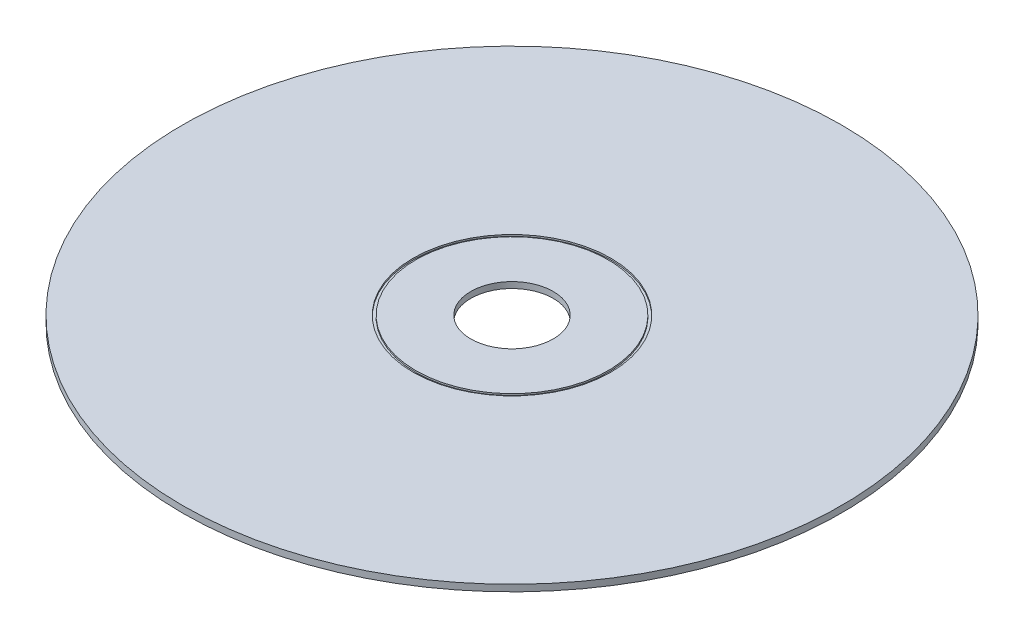
from build123d import *

# Parameters (mm, degrees)
SKETCH1_R           = 60
SKETCH1_R_2         = 7.5
BOSS_EXTRUDE1_DEPTH = 1.2
SKETCH2_R           = 18
SKETCH2_R_2         = 17.5
CUT_EXTRUDE1_DEPTH  = 0.3
SKETCH4_R           = 17.5
CUT_EXTRUDE2_DEPTH  = 0.1


with BuildPart() as part:
    # Sketch1 → Boss-Extrude1 (new body)
    with BuildSketch(Plane(origin=(0, 0, 0), x_dir=(1, 0, 0), z_dir=(0, 1, 0))):
        Circle(SKETCH1_R)
        Circle(SKETCH1_R_2, mode=Mode.SUBTRACT)
    extrude(amount=BOSS_EXTRUDE1_DEPTH)

    # Sketch2 → Cut-Extrude1 (cut)
    with BuildSketch(Plane(origin=(0, 1.2, 0), x_dir=(1, 0, 0), z_dir=(0, 1, 0))):
        Circle(SKETCH2_R)
        Circle(SKETCH2_R_2, mode=Mode.SUBTRACT)
    extrude(amount=-CUT_EXTRUDE1_DEPTH, mode=Mode.SUBTRACT)

    # Sketch4 → Cut-Extrude2 (cut)
    with BuildSketch(Plane.XZ):
        Circle(SKETCH4_R)
    extrude(amount=-CUT_EXTRUDE2_DEPTH, mode=Mode.SUBTRACT)


solid = part.part
